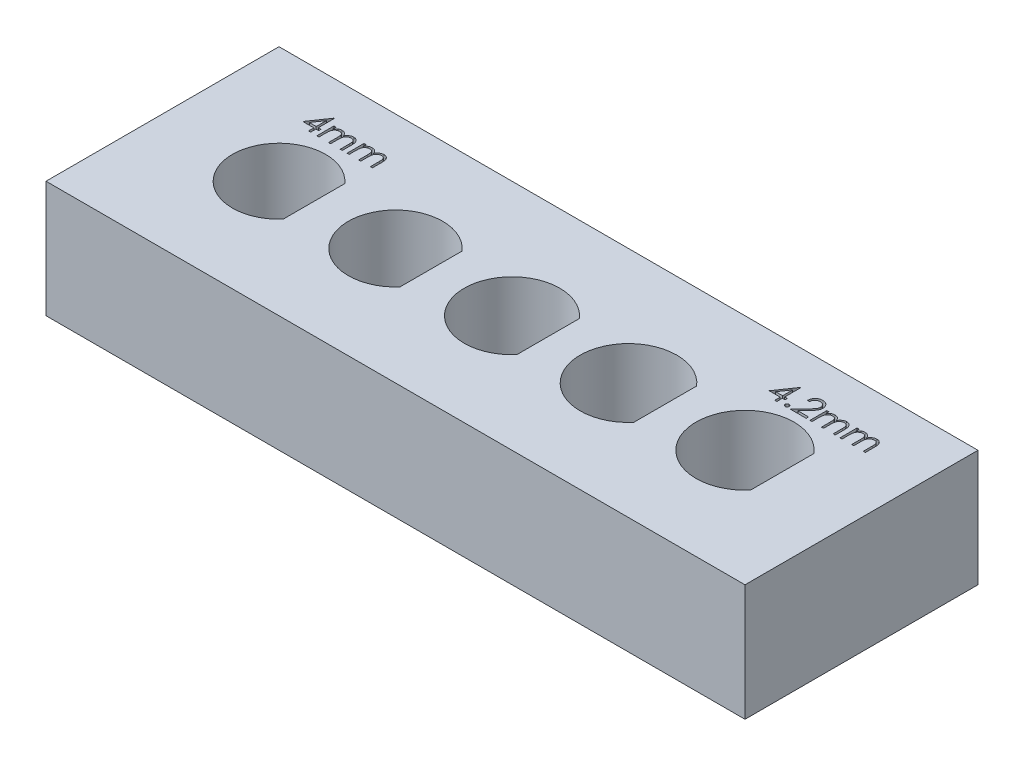
from build123d import *

# Parameters (mm, degrees)
SKETCH1_W           = 30
SKETCH1_H           = 10
BOSS_EXTRUDE1_DEPTH = 5
CUT_EXTRUDE1_DEPTH  = 0.5


with BuildPart() as part:
    # Sketch1 → Boss-Extrude1 (new body)
    with BuildSketch(Plane(origin=(0, 0, 0), x_dir=(1, 0, 0), z_dir=(0, 1, 0))):
        Rectangle(SKETCH1_W, SKETCH1_H)
        with BuildLine():
            ThreePointArc((11.6, 1.360147051), (7.9, 0), (11.6, -1.360147051))
            Line((11.6, -1.360147051), (11.6, 1.360147051))
        make_face(mode=Mode.SUBTRACT)
        with BuildLine():
            ThreePointArc((6.575, 1.350925609), (2.925, 0), (6.575, -1.350925609))
            Line((6.575, -1.350925609), (6.575, 1.350925609))
        make_face(mode=Mode.SUBTRACT)
        with BuildLine():
            ThreePointArc((1.55, 1.341640786), (-2.05, 0), (1.55, -1.341640786))
            Line((1.55, -1.341640786), (1.55, 1.341640786))
        make_face(mode=Mode.SUBTRACT)
        with BuildLine():
            ThreePointArc((-3.475, 1.332291259), (-7.025, 0), (-3.475, -1.332291259))
            Line((-3.475, -1.332291259), (-3.475, 1.332291259))
        make_face(mode=Mode.SUBTRACT)
        with BuildLine():
            ThreePointArc((-8.5, 1.322875656), (-12, 0), (-8.5, -1.322875656))
            Line((-8.5, -1.322875656), (-8.5, 1.322875656))
        make_face(mode=Mode.SUBTRACT)
    extrude(amount=-BOSS_EXTRUDE1_DEPTH)

    # Sketch2 → Cut-Extrude1 (cut)
    with BuildSketch(Plane(origin=(0, 0, 0), x_dir=(1, 0, 0), z_dir=(0, 1, 0))):
        Polygon((-11.16322467, 3.525641026), (-11.144995504, 3.525641026), (-11.144995504, 2.833333333), (-11.029610888, 2.833333333), (-11.029610888, 2.730769231), (-11.144995504, 2.730769231), (-11.144995504, 2.5), (-11.234739093, 2.5), (-11.234739093, 2.730769231), (-11.709098068, 2.730769231), align=None)
        Polygon((-11.234739093, 2.833333333), (-11.234739093, 3.267628205), (-11.532816016, 2.833333333), align=None, mode=Mode.SUBTRACT)
        with BuildLine():
            Line((-10.875764734, 3.230769231), (-10.786021145, 3.230769231))
            Line((-10.786021145, 3.230769231), (-10.786021145, 3.103766026))
            add(Edge.make_bspline(
                [(-10.786021145, 3.103766026), (-10.777940016, 3.114876769), (-10.762455799, 3.136166018), (-10.737065613, 3.164220385), (-10.711701009, 3.18802843), (-10.693434329, 3.200526393), (-10.684658965, 3.206530449)],
                knots=[0, 0, 0, 0, 4.1186e-05, 7.8917e-05, 0.000113372, 0.000145229, 0.000145229, 0.000145229, 0.000145229], degree=3))
            add(Edge.make_bspline(
                [(-10.684658965, 3.206530449), (-10.672697633, 3.212246267), (-10.648983947, 3.223578043), (-10.611435597, 3.235073345), (-10.573014263, 3.24213766), (-10.547069059, 3.243103767), (-10.534017939, 3.243589744)],
                knots=[0, 0, 0, 0, 3.9723e-05, 7.8752e-05, 0.000117418, 0.000156554, 0.000156554, 0.000156554, 0.000156554], degree=3))
            add(Edge.make_bspline(
                [(-10.534017939, 3.243589744), (-10.525191369, 3.243291089), (-10.507724061, 3.242700068), (-10.481842892, 3.238854344), (-10.456740432, 3.232206866), (-10.432564995, 3.22294763), (-10.409787658, 3.211734291), (-10.38890503, 3.198577232), (-10.370155256, 3.183806639), (-10.353547813, 3.166755515), (-10.338613806, 3.146945058), (-10.324876992, 3.123840987), (-10.312184074, 3.096924512), (-10.305149415, 3.077391215), (-10.301445824, 3.067107372)],
                knots=[0, 0, 0, 0, 2.6479e-05, 5.2401e-05, 7.8299e-05, 0.000104231, 0.000129942, 0.00015434, 0.000178148, 0.00020138, 0.000225539, 0.000252404, 0.000281885, 0.000314662, 0.000314662, 0.000314662, 0.000314662], degree=3))
            add(Edge.make_bspline(
                [(-10.301445824, 3.067107372), (-10.297528324, 3.074171492), (-10.289819233, 3.088072687), (-10.276874765, 3.107746477), (-10.263312538, 3.126148417), (-10.249016968, 3.14329311), (-10.234038515, 3.15909589), (-10.218306686, 3.173609005), (-10.201911034, 3.18689478), (-10.179113252, 3.202415683), (-10.149452507, 3.218901734), (-10.112055902, 3.233195576), (-10.073155853, 3.242028755), (-10.046750797, 3.243065976), (-10.033416978, 3.243589744)],
                knots=[0, 0, 0, 0, 2.4226e-05, 4.7672e-05, 7.059e-05, 9.2776e-05, 0.000114597, 0.000135861, 0.000156947, 0.000177839, 0.000218543, 0.000258425, 0.0002976, 0.000337563, 0.000337563, 0.000337563, 0.000337563], degree=3))
            add(Edge.make_bspline(
                [(-10.033416978, 3.243589744), (-10.021165131, 3.24312768), (-9.997187078, 3.242223378), (-9.962279288, 3.235122386), (-9.929724486, 3.222928772), (-9.899588179, 3.20629059), (-9.872399661, 3.185382252), (-9.84876643, 3.160505442), (-9.82883204, 3.131836121), (-9.815809572, 3.104866981), (-9.806976639, 3.081056886), (-9.801530572, 3.060769374), (-9.796719231, 3.038440359), (-9.792724589, 3.014043141), (-9.789805003, 2.987491539), (-9.787641941, 2.958829003), (-9.78617792, 2.928033257), (-9.786074471, 2.906785971), (-9.786021145, 2.895833333)],
                knots=[0, 0, 0, 0, 3.6737e-05, 7.1899e-05, 0.000106317, 0.000140658, 0.000174796, 0.000208802, 0.000243199, 0.000279124, 0.000298327, 0.000319323, 0.000342072, 0.000366837, 0.00039345, 0.00042218, 0.000453061, 0.000485916, 0.000485916, 0.000485916, 0.000485916], degree=3))
            Line((-9.786021145, 2.895833333), (-9.786021145, 2.5))
            Line((-9.786021145, 2.5), (-9.875764734, 2.5))
            Line((-9.875764734, 2.5), (-9.875764734, 2.896233974))
            add(Edge.make_bspline(
                [(-9.875764734, 2.896233974), (-9.875786987, 2.90558271), (-9.875829752, 2.923549557), (-9.876599361, 2.949335972), (-9.878049451, 2.972841217), (-9.879745062, 2.994033242), (-9.882100436, 3.012961467), (-9.885142131, 3.029587873), (-9.888364325, 3.044043247), (-9.893717465, 3.060067832), (-9.902274006, 3.077745035), (-9.915307572, 3.096808914), (-9.931727602, 3.113403429), (-9.950687647, 3.127808662), (-9.972272917, 3.139521131), (-9.996062837, 3.147885705), (-10.021909709, 3.15306367), (-10.039801935, 3.153579675), (-10.049041978, 3.153846154)],
                knots=[0, 0, 0, 0, 2.8046e-05, 5.3899e-05, 7.7379e-05, 9.8689e-05, 0.000117672, 0.000134568, 0.000149388, 0.000162057, 0.000185173, 0.000208067, 0.000231015, 0.000254894, 0.000279275, 0.000304365, 0.000330294, 0.000357985, 0.000357985, 0.000357985, 0.000357985], degree=3))
            add(Edge.make_bspline(
                [(-10.049041978, 3.153846154), (-10.060376251, 3.153441537), (-10.082777082, 3.152641862), (-10.115475793, 3.144477898), (-10.146896083, 3.132169255), (-10.176100407, 3.11433141), (-10.20296549, 3.092957592), (-10.226079655, 3.067543422), (-10.245174565, 3.038792014), (-10.258104273, 3.01217867), (-10.266272644, 2.988273115), (-10.271666049, 2.967388151), (-10.275861304, 2.943650561), (-10.27979574, 2.917219849), (-10.282363663, 2.887914083), (-10.284697483, 2.855868826), (-10.285789159, 2.820987694), (-10.285941861, 2.796808641), (-10.286021145, 2.784254808)],
                knots=[0, 0, 0, 0, 3.3939e-05, 6.7077e-05, 0.000100519, 0.000134839, 0.000169315, 0.000203205, 0.000237429, 0.000272551, 0.000291619, 0.000313143, 0.000337188, 0.000363903, 0.000393284, 0.000425411, 0.000460288, 0.00049795, 0.00049795, 0.00049795, 0.00049795], degree=3))
            Line((-10.286021145, 2.784254808), (-10.286021145, 2.5))
            Line((-10.286021145, 2.5), (-10.375764734, 2.5))
            Line((-10.375764734, 2.5), (-10.375764734, 2.871594551))
            add(Edge.make_bspline(
                [(-10.375764734, 2.871594551), (-10.375787429, 2.882078357), (-10.375831091, 2.902248144), (-10.376595753, 2.931172052), (-10.378049074, 2.957480932), (-10.37972923, 2.981144207), (-10.382146424, 3.002118872), (-10.38489207, 3.020517375), (-10.388134531, 3.036293589), (-10.393503069, 3.053597414), (-10.401707203, 3.072660534), (-10.414903849, 3.09298654), (-10.431363158, 3.110777425), (-10.450669122, 3.125965639), (-10.472385031, 3.138520348), (-10.496380289, 3.147565992), (-10.522438835, 3.152830074), (-10.540403894, 3.153501073), (-10.549642939, 3.153846154)],
                knots=[0, 0, 0, 0, 3.1451e-05, 6.0508e-05, 8.6788e-05, 0.000110494, 0.000131665, 0.000150109, 0.000166296, 0.000179919, 0.000204409, 0.000228301, 0.00025226, 0.000276787, 0.000301733, 0.000327219, 0.000353384, 0.000381087, 0.000381087, 0.000381087, 0.000381087], degree=3))
            add(Edge.make_bspline(
                [(-10.549642939, 3.153846154), (-10.560504714, 3.15340888), (-10.582151845, 3.152537407), (-10.613952408, 3.144693329), (-10.644662603, 3.132406451), (-10.673792517, 3.115360788), (-10.70055656, 3.094246766), (-10.723987493, 3.069413938), (-10.743685358, 3.041171357), (-10.756751591, 3.014838638), (-10.765179726, 2.991531988), (-10.770778393, 2.971717432), (-10.775589715, 2.949717361), (-10.77916515, 2.925463901), (-10.782616697, 2.899115017), (-10.784282499, 2.870539448), (-10.785902946, 2.839761709), (-10.785980779, 2.81851241), (-10.786021145, 2.807491987)],
                knots=[0, 0, 0, 0, 3.2541e-05, 6.4853e-05, 9.7662e-05, 0.000131504, 0.00016573, 0.000199599, 0.000233553, 0.000268671, 0.000287428, 0.000307845, 0.000330399, 0.000354935, 0.000381372, 0.000410087, 0.000440769, 0.000473824, 0.000473824, 0.000473824, 0.000473824], degree=3))
            Line((-10.786021145, 2.807491987), (-10.786021145, 2.5))
            Line((-10.786021145, 2.5), (-10.875764734, 2.5))
            Line((-10.875764734, 2.5), (-10.875764734, 3.230769231))
        make_face()
        with BuildLine():
            Line((-9.580892939, 3.230769231), (-9.49114935, 3.230769231))
            Line((-9.49114935, 3.230769231), (-9.49114935, 3.103766026))
            add(Edge.make_bspline(
                [(-9.49114935, 3.103766026), (-9.483068221, 3.114876769), (-9.467584004, 3.136166018), (-9.442193818, 3.164220385), (-9.416829214, 3.18802843), (-9.398562534, 3.200526393), (-9.38978717, 3.206530449)],
                knots=[0, 0, 0, 0, 4.1186e-05, 7.8917e-05, 0.000113372, 0.000145229, 0.000145229, 0.000145229, 0.000145229], degree=3))
            add(Edge.make_bspline(
                [(-9.38978717, 3.206530449), (-9.377825838, 3.212246267), (-9.354112153, 3.223578043), (-9.316563803, 3.235073345), (-9.278142468, 3.24213766), (-9.252197264, 3.243103767), (-9.239146145, 3.243589744)],
                knots=[0, 0, 0, 0, 3.9723e-05, 7.8752e-05, 0.000117418, 0.000156554, 0.000156554, 0.000156554, 0.000156554], degree=3))
            add(Edge.make_bspline(
                [(-9.239146145, 3.243589744), (-9.230319574, 3.243291089), (-9.212852266, 3.242700068), (-9.186971097, 3.238854344), (-9.161868637, 3.232206866), (-9.1376932, 3.22294763), (-9.114915863, 3.211734291), (-9.094033235, 3.198577232), (-9.075283461, 3.183806639), (-9.058676018, 3.166755515), (-9.043742011, 3.146945058), (-9.030005197, 3.123840987), (-9.01731228, 3.096924512), (-9.01027762, 3.077391215), (-9.006574029, 3.067107372)],
                knots=[0, 0, 0, 0, 2.6479e-05, 5.2401e-05, 7.8299e-05, 0.000104231, 0.000129942, 0.00015434, 0.000178148, 0.00020138, 0.000225539, 0.000252404, 0.000281885, 0.000314662, 0.000314662, 0.000314662, 0.000314662], degree=3))
            add(Edge.make_bspline(
                [(-9.006574029, 3.067107372), (-9.002656529, 3.074171492), (-8.994947438, 3.088072687), (-8.98200297, 3.107746477), (-8.968440743, 3.126148417), (-8.954145173, 3.14329311), (-8.93916672, 3.15909589), (-8.923434891, 3.173609005), (-8.90703924, 3.18689478), (-8.884241457, 3.202415683), (-8.854580712, 3.218901734), (-8.817184108, 3.233195576), (-8.778284059, 3.242028755), (-8.751879002, 3.243065976), (-8.738545183, 3.243589744)],
                knots=[0, 0, 0, 0, 2.4226e-05, 4.7672e-05, 7.059e-05, 9.2776e-05, 0.000114597, 0.000135861, 0.000156947, 0.000177839, 0.000218543, 0.000258425, 0.0002976, 0.000337563, 0.000337563, 0.000337563, 0.000337563], degree=3))
            add(Edge.make_bspline(
                [(-8.738545183, 3.243589744), (-8.726293337, 3.24312768), (-8.702315283, 3.242223378), (-8.667407493, 3.235122386), (-8.634852692, 3.222928772), (-8.604716384, 3.20629059), (-8.577527866, 3.185382252), (-8.553894635, 3.160505442), (-8.533960245, 3.131836121), (-8.520937777, 3.104866981), (-8.512104844, 3.081056886), (-8.506658777, 3.060769374), (-8.501847436, 3.038440359), (-8.497852794, 3.014043141), (-8.494933208, 2.987491539), (-8.492770146, 2.958829003), (-8.491306125, 2.928033257), (-8.491202676, 2.906785971), (-8.49114935, 2.895833333)],
                knots=[0, 0, 0, 0, 3.6737e-05, 7.1899e-05, 0.000106317, 0.000140658, 0.000174796, 0.000208802, 0.000243199, 0.000279124, 0.000298327, 0.000319323, 0.000342072, 0.000366837, 0.00039345, 0.00042218, 0.000453061, 0.000485916, 0.000485916, 0.000485916, 0.000485916], degree=3))
            Line((-8.49114935, 2.895833333), (-8.49114935, 2.5))
            Line((-8.49114935, 2.5), (-8.580892939, 2.5))
            Line((-8.580892939, 2.5), (-8.580892939, 2.896233974))
            add(Edge.make_bspline(
                [(-8.580892939, 2.896233974), (-8.580915192, 2.90558271), (-8.580957957, 2.923549557), (-8.581727566, 2.949335972), (-8.583177656, 2.972841217), (-8.584873267, 2.994033242), (-8.587228641, 3.012961467), (-8.590270336, 3.029587873), (-8.59349253, 3.044043247), (-8.598845671, 3.060067832), (-8.607402211, 3.077745035), (-8.620435777, 3.096808914), (-8.636855807, 3.113403429), (-8.655815852, 3.127808662), (-8.677401122, 3.139521131), (-8.701191043, 3.147885705), (-8.727037915, 3.15306367), (-8.74493014, 3.153579675), (-8.754170183, 3.153846154)],
                knots=[0, 0, 0, 0, 2.8046e-05, 5.3899e-05, 7.7379e-05, 9.8689e-05, 0.000117672, 0.000134568, 0.000149388, 0.000162057, 0.000185173, 0.000208067, 0.000231015, 0.000254894, 0.000279275, 0.000304365, 0.000330294, 0.000357985, 0.000357985, 0.000357985, 0.000357985], degree=3))
            add(Edge.make_bspline(
                [(-8.754170183, 3.153846154), (-8.765504456, 3.153441537), (-8.787905287, 3.152641862), (-8.820603998, 3.144477898), (-8.852024288, 3.132169255), (-8.881228612, 3.11433141), (-8.908093695, 3.092957592), (-8.93120786, 3.067543422), (-8.95030277, 3.038792014), (-8.963232478, 3.01217867), (-8.971400849, 2.988273115), (-8.976794254, 2.967388151), (-8.980989509, 2.943650561), (-8.984923946, 2.917219849), (-8.987491868, 2.887914083), (-8.989825689, 2.855868826), (-8.990917364, 2.820987694), (-8.991070066, 2.796808641), (-8.99114935, 2.784254808)],
                knots=[0, 0, 0, 0, 3.3939e-05, 6.7077e-05, 0.000100519, 0.000134839, 0.000169315, 0.000203205, 0.000237429, 0.000272551, 0.000291619, 0.000313143, 0.000337188, 0.000363903, 0.000393284, 0.000425411, 0.000460288, 0.00049795, 0.00049795, 0.00049795, 0.00049795], degree=3))
            Line((-8.99114935, 2.784254808), (-8.99114935, 2.5))
            Line((-8.99114935, 2.5), (-9.080892939, 2.5))
            Line((-9.080892939, 2.5), (-9.080892939, 2.871594551))
            add(Edge.make_bspline(
                [(-9.080892939, 2.871594551), (-9.080915634, 2.882078357), (-9.080959296, 2.902248144), (-9.081723958, 2.931172052), (-9.083177279, 2.957480932), (-9.084857435, 2.981144207), (-9.087274629, 3.002118872), (-9.090020276, 3.020517375), (-9.093262736, 3.036293589), (-9.098631274, 3.053597414), (-9.106835408, 3.072660534), (-9.120032054, 3.09298654), (-9.136491363, 3.110777425), (-9.155797327, 3.125965639), (-9.177513237, 3.138520348), (-9.201508494, 3.147565992), (-9.227567041, 3.152830074), (-9.245532099, 3.153501073), (-9.254771145, 3.153846154)],
                knots=[0, 0, 0, 0, 3.1451e-05, 6.0508e-05, 8.6788e-05, 0.000110494, 0.000131665, 0.000150109, 0.000166296, 0.000179919, 0.000204409, 0.000228301, 0.00025226, 0.000276787, 0.000301733, 0.000327219, 0.000353384, 0.000381087, 0.000381087, 0.000381087, 0.000381087], degree=3))
            add(Edge.make_bspline(
                [(-9.254771145, 3.153846154), (-9.265632919, 3.15340888), (-9.287280051, 3.152537407), (-9.319080613, 3.144693329), (-9.349790809, 3.132406451), (-9.378920723, 3.115360788), (-9.405684765, 3.094246766), (-9.429115698, 3.069413938), (-9.448813563, 3.041171357), (-9.461879796, 3.014838638), (-9.470307931, 2.991531988), (-9.475906598, 2.971717432), (-9.48071792, 2.949717361), (-9.484293355, 2.925463901), (-9.487744902, 2.899115017), (-9.489410705, 2.870539448), (-9.491031151, 2.839761709), (-9.491108984, 2.81851241), (-9.49114935, 2.807491987)],
                knots=[0, 0, 0, 0, 3.2541e-05, 6.4853e-05, 9.7662e-05, 0.000131504, 0.00016573, 0.000199599, 0.000233553, 0.000268671, 0.000287428, 0.000307845, 0.000330399, 0.000354935, 0.000381372, 0.000410087, 0.000440769, 0.000473824, 0.000473824, 0.000473824, 0.000473824], degree=3))
            Line((-9.49114935, 2.807491987), (-9.49114935, 2.5))
            Line((-9.49114935, 2.5), (-9.580892939, 2.5))
            Line((-9.580892939, 2.5), (-9.580892939, 3.230769231))
        make_face()
        Polygon((8.852364677, 3.525641026), (8.870593843, 3.525641026), (8.870593843, 2.833333333), (8.985978459, 2.833333333), (8.985978459, 2.730769231), (8.870593843, 2.730769231), (8.870593843, 2.5), (8.780850254, 2.5), (8.780850254, 2.730769231), (8.306491279, 2.730769231), align=None)
        Polygon((8.780850254, 2.833333333), (8.780850254, 3.267628205), (8.48277333, 2.833333333), align=None, mode=Mode.SUBTRACT)
        with BuildLine():
            add(Edge.make_bspline(
                [(9.235978459, 2.653846154), (9.241547091, 2.653515249), (9.252463743, 2.652866549), (9.268246351, 2.648416071), (9.282530539, 2.640513596), (9.295254038, 2.629981374), (9.305741603, 2.617211184), (9.313925703, 2.603040925), (9.318337413, 2.587126184), (9.318981388, 2.576146277), (9.319311792, 2.570512821)],
                knots=[0, 0, 0, 0, 1.6704e-05, 3.2746e-05, 4.8701e-05, 6.5347e-05, 8.1993e-05, 9.8045e-05, 0.000114087, 0.00013099, 0.00013099, 0.00013099, 0.00013099], degree=3))
            add(Edge.make_bspline(
                [(9.319311792, 2.570512821), (9.318970192, 2.565014726), (9.318296561, 2.554172565), (9.313935816, 2.538377862), (9.30567923, 2.524198746), (9.295326375, 2.511255278), (9.282527394, 2.500700744), (9.268212581, 2.492865502), (9.252500793, 2.488096365), (9.241553272, 2.487488852), (9.235978459, 2.487179487)],
                knots=[0, 0, 0, 0, 1.6504e-05, 3.2546e-05, 4.8598e-05, 6.5399e-05, 8.2045e-05, 9.8e-05, 0.000114098, 0.000130802, 0.000130802, 0.000130802, 0.000130802], degree=3))
            add(Edge.make_bspline(
                [(9.235978459, 2.487179487), (9.230399628, 2.487477658), (9.219508291, 2.488059765), (9.203855149, 2.492963424), (9.189453158, 2.50062727), (9.176656669, 2.511274958), (9.166217106, 2.524132142), (9.158324139, 2.538475512), (9.153584097, 2.554127352), (9.152960705, 2.565005821), (9.152645125, 2.570512821)],
                knots=[0, 0, 0, 0, 1.6704e-05, 3.261e-05, 4.8742e-05, 6.5388e-05, 8.2188e-05, 9.8144e-05, 0.000114242, 0.000130746, 0.000130746, 0.000130746, 0.000130746], degree=3))
            add(Edge.make_bspline(
                [(9.152645125, 2.570512821), (9.152948582, 2.5761555), (9.153541045, 2.58717214), (9.15833409, 2.602943314), (9.166155865, 2.617277154), (9.176728835, 2.629961891), (9.189450063, 2.640586835), (9.203820407, 2.648319633), (9.21954599, 2.652902608), (9.230405972, 2.653526184), (9.235978459, 2.653846154)],
                knots=[0, 0, 0, 0, 1.6903e-05, 3.3001e-05, 4.8957e-05, 6.5602e-05, 8.2248e-05, 9.838e-05, 0.000114229, 0.000130933, 0.000130933, 0.000130933, 0.000130933], degree=3))
        make_face()
        with BuildLine():
            Line((9.575722048, 3.192307692), (9.485978459, 3.192307692))
            add(Edge.make_bspline(
                [(9.485978459, 3.192307692), (9.48656336, 3.20421366), (9.487712089, 3.227596664), (9.4930916, 3.261689209), (9.500788994, 3.294276294), (9.511672267, 3.32509627), (9.525188346, 3.354421643), (9.541396925, 3.382135934), (9.560595168, 3.408133416), (9.582368521, 3.432173086), (9.606016703, 3.454226677), (9.631532686, 3.473271032), (9.658345551, 3.489361796), (9.686373951, 3.502813579), (9.715934112, 3.512910678), (9.746757785, 3.520402575), (9.778980396, 3.524910102), (9.800934688, 3.525394612), (9.812100254, 3.525641026)],
                knots=[0, 0, 0, 0, 3.5738e-05, 7.0188e-05, 0.000103373, 0.000136064, 0.000168061, 0.000200116, 0.000232208, 0.000264831, 0.000297294, 0.000329065, 0.000360156, 0.00039098, 0.000422149, 0.000453681, 0.000486034, 0.000519517, 0.000519517, 0.000519517, 0.000519517], degree=3))
            add(Edge.make_bspline(
                [(9.812100254, 3.525641026), (9.823065418, 3.525384324), (9.844611573, 3.524879914), (9.876057863, 3.520548191), (9.905994233, 3.513763736), (9.934362166, 3.504245046), (9.960935327, 3.491449495), (9.98591334, 3.47607877), (10.009593572, 3.458301675), (10.030909796, 3.437372014), (10.050483533, 3.415028476), (10.067369891, 3.391174789), (10.081830795, 3.36653785), (10.093884418, 3.340929793), (10.1027576, 3.314109499), (10.109494231, 3.286467441), (10.113302064, 3.257717495), (10.113886471, 3.238258479), (10.114183587, 3.228365385)],
                knots=[0, 0, 0, 0, 3.2882e-05, 6.4613e-05, 9.5033e-05, 0.00012487, 0.000154169, 0.000183303, 0.000212751, 0.000242786, 0.000272749, 0.000301764, 0.000330315, 0.000358367, 0.000386493, 0.000414917, 0.000443616, 0.000473296, 0.000473296, 0.000473296, 0.000473296], degree=3))
            add(Edge.make_bspline(
                [(10.114183587, 3.228365385), (10.113699797, 3.214437432), (10.112740709, 3.186825942), (10.104536601, 3.146250267), (10.091723312, 3.106937862), (10.076295496, 3.075298633), (10.06073194, 3.049803349), (10.046706938, 3.02881229), (10.030288421, 3.006210728), (10.011237421, 2.982074346), (9.989948029, 2.956214087), (9.966227411, 2.928645574), (9.939906416, 2.89965364), (9.921432559, 2.879852039), (9.911859869, 2.869591346)],
                knots=[0, 0, 0, 0, 4.1748e-05, 8.2763e-05, 0.000123686, 0.000165526, 0.000187994, 0.000213273, 0.000241241, 0.000271777, 0.000305505, 0.000341726, 0.000380871, 0.000422969, 0.000422969, 0.000422969, 0.000422969], degree=3))
            Line((9.911859869, 2.869591346), (9.661659548, 2.602564103))
            Line((9.661659548, 2.602564103), (10.1270041, 2.602564103))
            Line((10.1270041, 2.602564103), (10.1270041, 2.5))
            Line((10.1270041, 2.5), (9.44751692, 2.5))
            Line((9.44751692, 2.5), (9.835337433, 2.913862179))
            add(Edge.make_bspline(
                [(9.835337433, 2.913862179), (9.844779686, 2.923718839), (9.862916323, 2.942651463), (9.888568487, 2.970292309), (9.911608198, 2.995935035), (9.932184596, 3.019531192), (9.949851312, 3.041425925), (9.965529093, 3.060910126), (9.97809069, 3.078839969), (9.99172366, 3.099623002), (10.004927655, 3.12499795), (10.016274042, 3.156007575), (10.023192571, 3.187929647), (10.024022524, 3.209501658), (10.024439997, 3.220352564)],
                knots=[0, 0, 0, 0, 4.0948e-05, 7.8653e-05, 0.000113123, 0.000144368, 0.000172557, 0.000197523, 0.000219366, 0.000238203, 0.000272071, 0.000304896, 0.000337034, 0.00036956, 0.00036956, 0.00036956, 0.00036956], degree=3))
            add(Edge.make_bspline(
                [(10.024439997, 3.220352564), (10.024258356, 3.227175821), (10.023900378, 3.240623149), (10.020741035, 3.260339081), (10.015966605, 3.279357599), (10.009125103, 3.297737204), (10.000094606, 3.315293105), (9.989102211, 3.332046671), (9.976419336, 3.348243518), (9.961747545, 3.363430174), (9.945629968, 3.37733909), (9.928603039, 3.389660258), (9.910588724, 3.399957146), (9.891662975, 3.408398146), (9.871878555, 3.415019683), (9.851197199, 3.419607849), (9.829676052, 3.422488558), (9.814980767, 3.422878322), (9.807492882, 3.423076923)],
                knots=[0, 0, 0, 0, 2.0457e-05, 4.0317e-05, 5.9751e-05, 7.9211e-05, 9.9011e-05, 0.000118847, 0.000139245, 0.000160638, 0.000182083, 0.000203042, 0.00022359, 0.000244214, 0.000265119, 0.000286064, 0.000307681, 0.00033014, 0.00033014, 0.00033014, 0.00033014], degree=3))
            add(Edge.make_bspline(
                [(9.807492882, 3.423076923), (9.799672644, 3.422872628), (9.784314988, 3.422471427), (9.761766693, 3.419664951), (9.74025647, 3.414823283), (9.719730212, 3.408201376), (9.700153188, 3.399784647), (9.681620604, 3.389301292), (9.664174064, 3.376791722), (9.647780772, 3.362608706), (9.632676778, 3.346817963), (9.619406242, 3.329215116), (9.607810809, 3.310121569), (9.597693885, 3.28958884), (9.589477974, 3.267430617), (9.583199931, 3.243725559), (9.57823226, 3.218576593), (9.576572683, 3.201209426), (9.575722048, 3.192307692)],
                knots=[0, 0, 0, 0, 2.3459e-05, 4.6069e-05, 6.8036e-05, 8.9512e-05, 0.000110686, 0.000131856, 0.000153256, 0.000174984, 0.000196805, 0.000218681, 0.000240978, 0.000263733, 0.000287249, 0.000311741, 0.000337238, 0.00036405, 0.00036405, 0.00036405, 0.00036405], degree=3))
        make_face()
        with BuildLine():
            Line((10.280850254, 3.230769231), (10.370593843, 3.230769231))
            Line((10.370593843, 3.230769231), (10.370593843, 3.103766026))
            add(Edge.make_bspline(
                [(10.370593843, 3.103766026), (10.378674972, 3.114876769), (10.394159189, 3.136166018), (10.419549375, 3.164220385), (10.444913979, 3.18802843), (10.463180659, 3.200526393), (10.471956023, 3.206530449)],
                knots=[0, 0, 0, 0, 4.1186e-05, 7.8917e-05, 0.000113372, 0.000145229, 0.000145229, 0.000145229, 0.000145229], degree=3))
            add(Edge.make_bspline(
                [(10.471956023, 3.206530449), (10.483917355, 3.212246267), (10.50763104, 3.223578043), (10.54517939, 3.235073345), (10.583600725, 3.24213766), (10.609545929, 3.243103767), (10.622597048, 3.243589744)],
                knots=[0, 0, 0, 0, 3.9723e-05, 7.8752e-05, 0.000117418, 0.000156554, 0.000156554, 0.000156554, 0.000156554], degree=3))
            add(Edge.make_bspline(
                [(10.622597048, 3.243589744), (10.631423619, 3.243291089), (10.648890927, 3.242700068), (10.674772096, 3.238854344), (10.699874556, 3.232206866), (10.724049993, 3.22294763), (10.74682733, 3.211734291), (10.767709958, 3.198577232), (10.786459732, 3.183806639), (10.803067175, 3.166755515), (10.818001182, 3.146945058), (10.831737996, 3.123840987), (10.844430913, 3.096924512), (10.851465573, 3.077391215), (10.855169164, 3.067107372)],
                knots=[0, 0, 0, 0, 2.6479e-05, 5.2401e-05, 7.8299e-05, 0.000104231, 0.000129942, 0.00015434, 0.000178148, 0.00020138, 0.000225539, 0.000252404, 0.000281885, 0.000314662, 0.000314662, 0.000314662, 0.000314662], degree=3))
            add(Edge.make_bspline(
                [(10.855169164, 3.067107372), (10.859086664, 3.074171492), (10.866795755, 3.088072687), (10.879740223, 3.107746477), (10.89330245, 3.126148417), (10.90759802, 3.14329311), (10.922576473, 3.15909589), (10.938308302, 3.173609005), (10.954703953, 3.18689478), (10.977501736, 3.202415683), (11.007162481, 3.218901734), (11.044559085, 3.233195576), (11.083459134, 3.242028755), (11.109864191, 3.243065976), (11.12319801, 3.243589744)],
                knots=[0, 0, 0, 0, 2.4226e-05, 4.7672e-05, 7.059e-05, 9.2776e-05, 0.000114597, 0.000135861, 0.000156947, 0.000177839, 0.000218543, 0.000258425, 0.0002976, 0.000337563, 0.000337563, 0.000337563, 0.000337563], degree=3))
            add(Edge.make_bspline(
                [(11.12319801, 3.243589744), (11.135449856, 3.24312768), (11.15942791, 3.242223378), (11.1943357, 3.235122386), (11.226890501, 3.222928772), (11.257026809, 3.20629059), (11.284215327, 3.185382252), (11.307848558, 3.160505442), (11.327782948, 3.131836121), (11.340805416, 3.104866981), (11.349638349, 3.081056886), (11.355084416, 3.060769374), (11.359895757, 3.038440359), (11.363890399, 3.014043141), (11.366809985, 2.987491539), (11.368973047, 2.958829003), (11.370437068, 2.928033257), (11.370540517, 2.906785971), (11.370593843, 2.895833333)],
                knots=[0, 0, 0, 0, 3.6737e-05, 7.1899e-05, 0.000106317, 0.000140658, 0.000174796, 0.000208802, 0.000243199, 0.000279124, 0.000298327, 0.000319323, 0.000342072, 0.000366837, 0.00039345, 0.00042218, 0.000453061, 0.000485916, 0.000485916, 0.000485916, 0.000485916], degree=3))
            Line((11.370593843, 2.895833333), (11.370593843, 2.5))
            Line((11.370593843, 2.5), (11.280850254, 2.5))
            Line((11.280850254, 2.5), (11.280850254, 2.896233974))
            add(Edge.make_bspline(
                [(11.280850254, 2.896233974), (11.280828001, 2.90558271), (11.280785236, 2.923549557), (11.280015627, 2.949335972), (11.278565537, 2.972841217), (11.276869926, 2.994033242), (11.274514552, 3.012961467), (11.271472857, 3.029587873), (11.268250663, 3.044043247), (11.262897522, 3.060067832), (11.254340982, 3.077745035), (11.241307416, 3.096808914), (11.224887386, 3.113403429), (11.205927341, 3.127808662), (11.184342071, 3.139521131), (11.16055215, 3.147885705), (11.134705278, 3.15306367), (11.116813053, 3.153579675), (11.10757301, 3.153846154)],
                knots=[0, 0, 0, 0, 2.8046e-05, 5.3899e-05, 7.7379e-05, 9.8689e-05, 0.000117672, 0.000134568, 0.000149388, 0.000162057, 0.000185173, 0.000208067, 0.000231015, 0.000254894, 0.000279275, 0.000304365, 0.000330294, 0.000357985, 0.000357985, 0.000357985, 0.000357985], degree=3))
            add(Edge.make_bspline(
                [(11.10757301, 3.153846154), (11.096238737, 3.153441537), (11.073837905, 3.152641862), (11.041139195, 3.144477898), (11.009718905, 3.132169255), (10.980514581, 3.11433141), (10.953649498, 3.092957592), (10.930535333, 3.067543422), (10.911440423, 3.038792014), (10.898510715, 3.01217867), (10.890342343, 2.988273115), (10.884948939, 2.967388151), (10.880753684, 2.943650561), (10.876819247, 2.917219849), (10.874251325, 2.887914083), (10.871917504, 2.855868826), (10.870825829, 2.820987694), (10.870673127, 2.796808641), (10.870593843, 2.784254808)],
                knots=[0, 0, 0, 0, 3.3939e-05, 6.7077e-05, 0.000100519, 0.000134839, 0.000169315, 0.000203205, 0.000237429, 0.000272551, 0.000291619, 0.000313143, 0.000337188, 0.000363903, 0.000393284, 0.000425411, 0.000460288, 0.00049795, 0.00049795, 0.00049795, 0.00049795], degree=3))
            Line((10.870593843, 2.784254808), (10.870593843, 2.5))
            Line((10.870593843, 2.5), (10.780850254, 2.5))
            Line((10.780850254, 2.5), (10.780850254, 2.871594551))
            add(Edge.make_bspline(
                [(10.780850254, 2.871594551), (10.780827559, 2.882078357), (10.780783897, 2.902248144), (10.780019235, 2.931172052), (10.778565914, 2.957480932), (10.776885758, 2.981144207), (10.774468564, 3.002118872), (10.771722917, 3.020517375), (10.768480457, 3.036293589), (10.763111919, 3.053597414), (10.754907785, 3.072660534), (10.741711139, 3.09298654), (10.72525183, 3.110777425), (10.705945866, 3.125965639), (10.684229956, 3.138520348), (10.660234699, 3.147565992), (10.634176152, 3.152830074), (10.616211094, 3.153501073), (10.606972048, 3.153846154)],
                knots=[0, 0, 0, 0, 3.1451e-05, 6.0508e-05, 8.6788e-05, 0.000110494, 0.000131665, 0.000150109, 0.000166296, 0.000179919, 0.000204409, 0.000228301, 0.00025226, 0.000276787, 0.000301733, 0.000327219, 0.000353384, 0.000381087, 0.000381087, 0.000381087, 0.000381087], degree=3))
            add(Edge.make_bspline(
                [(10.606972048, 3.153846154), (10.596110274, 3.15340888), (10.574463142, 3.152537407), (10.54266258, 3.144693329), (10.511952384, 3.132406451), (10.48282247, 3.115360788), (10.456058428, 3.094246766), (10.432627495, 3.069413938), (10.41292963, 3.041171357), (10.399863397, 3.014838638), (10.391435262, 2.991531988), (10.385836595, 2.971717432), (10.381025273, 2.949717361), (10.377449838, 2.925463901), (10.373998291, 2.899115017), (10.372332488, 2.870539448), (10.370712042, 2.839761709), (10.370634209, 2.81851241), (10.370593843, 2.807491987)],
                knots=[0, 0, 0, 0, 3.2541e-05, 6.4853e-05, 9.7662e-05, 0.000131504, 0.00016573, 0.000199599, 0.000233553, 0.000268671, 0.000287428, 0.000307845, 0.000330399, 0.000354935, 0.000381372, 0.000410087, 0.000440769, 0.000473824, 0.000473824, 0.000473824, 0.000473824], degree=3))
            Line((10.370593843, 2.807491987), (10.370593843, 2.5))
            Line((10.370593843, 2.5), (10.280850254, 2.5))
            Line((10.280850254, 2.5), (10.280850254, 3.230769231))
        make_face()
        with BuildLine():
            Line((11.575722048, 3.230769231), (11.665465638, 3.230769231))
            Line((11.665465638, 3.230769231), (11.665465638, 3.103766026))
            add(Edge.make_bspline(
                [(11.665465638, 3.103766026), (11.673546767, 3.114876769), (11.689030984, 3.136166018), (11.71442117, 3.164220385), (11.739785774, 3.18802843), (11.758052454, 3.200526393), (11.766827818, 3.206530449)],
                knots=[0, 0, 0, 0, 4.1186e-05, 7.8917e-05, 0.000113372, 0.000145229, 0.000145229, 0.000145229, 0.000145229], degree=3))
            add(Edge.make_bspline(
                [(11.766827818, 3.206530449), (11.77878915, 3.212246267), (11.802502835, 3.223578043), (11.840051185, 3.235073345), (11.878472519, 3.24213766), (11.904417723, 3.243103767), (11.917468843, 3.243589744)],
                knots=[0, 0, 0, 0, 3.9723e-05, 7.8752e-05, 0.000117418, 0.000156554, 0.000156554, 0.000156554, 0.000156554], degree=3))
            add(Edge.make_bspline(
                [(11.917468843, 3.243589744), (11.926295414, 3.243291089), (11.943762722, 3.242700068), (11.969643891, 3.238854344), (11.994746351, 3.232206866), (12.018921788, 3.22294763), (12.041699125, 3.211734291), (12.062581753, 3.198577232), (12.081331527, 3.183806639), (12.09793897, 3.166755515), (12.112872977, 3.146945058), (12.126609791, 3.123840987), (12.139302708, 3.096924512), (12.146337368, 3.077391215), (12.150040959, 3.067107372)],
                knots=[0, 0, 0, 0, 2.6479e-05, 5.2401e-05, 7.8299e-05, 0.000104231, 0.000129942, 0.00015434, 0.000178148, 0.00020138, 0.000225539, 0.000252404, 0.000281885, 0.000314662, 0.000314662, 0.000314662, 0.000314662], degree=3))
            add(Edge.make_bspline(
                [(12.150040959, 3.067107372), (12.153958459, 3.074171492), (12.16166755, 3.088072687), (12.174612017, 3.107746477), (12.188174245, 3.126148417), (12.202469814, 3.14329311), (12.217448268, 3.15909589), (12.233180096, 3.173609005), (12.249575748, 3.18689478), (12.272373531, 3.202415683), (12.302034276, 3.218901734), (12.33943088, 3.233195576), (12.378330929, 3.242028755), (12.404735986, 3.243065976), (12.418069805, 3.243589744)],
                knots=[0, 0, 0, 0, 2.4226e-05, 4.7672e-05, 7.059e-05, 9.2776e-05, 0.000114597, 0.000135861, 0.000156947, 0.000177839, 0.000218543, 0.000258425, 0.0002976, 0.000337563, 0.000337563, 0.000337563, 0.000337563], degree=3))
            add(Edge.make_bspline(
                [(12.418069805, 3.243589744), (12.430321651, 3.24312768), (12.454299705, 3.242223378), (12.489207495, 3.235122386), (12.521762296, 3.222928772), (12.551898604, 3.20629059), (12.579087122, 3.185382252), (12.602720353, 3.160505442), (12.622654743, 3.131836121), (12.635677211, 3.104866981), (12.644510144, 3.081056886), (12.649956211, 3.060769374), (12.654767552, 3.038440359), (12.658762194, 3.014043141), (12.66168178, 2.987491539), (12.663844841, 2.958829003), (12.665308862, 2.928033257), (12.665412312, 2.906785971), (12.665465638, 2.895833333)],
                knots=[0, 0, 0, 0, 3.6737e-05, 7.1899e-05, 0.000106317, 0.000140658, 0.000174796, 0.000208802, 0.000243199, 0.000279124, 0.000298327, 0.000319323, 0.000342072, 0.000366837, 0.00039345, 0.00042218, 0.000453061, 0.000485916, 0.000485916, 0.000485916, 0.000485916], degree=3))
            Line((12.665465638, 2.895833333), (12.665465638, 2.5))
            Line((12.665465638, 2.5), (12.575722048, 2.5))
            Line((12.575722048, 2.5), (12.575722048, 2.896233974))
            add(Edge.make_bspline(
                [(12.575722048, 2.896233974), (12.575699796, 2.90558271), (12.575657031, 2.923549557), (12.574887422, 2.949335972), (12.573437332, 2.972841217), (12.571741721, 2.994033242), (12.569386347, 3.012961467), (12.566344652, 3.029587873), (12.563122458, 3.044043247), (12.557769317, 3.060067832), (12.549212777, 3.077745035), (12.536179211, 3.096808914), (12.519759181, 3.113403429), (12.500799136, 3.127808662), (12.479213866, 3.139521131), (12.455423945, 3.147885705), (12.429577073, 3.15306367), (12.411684848, 3.153579675), (12.402444805, 3.153846154)],
                knots=[0, 0, 0, 0, 2.8046e-05, 5.3899e-05, 7.7379e-05, 9.8689e-05, 0.000117672, 0.000134568, 0.000149388, 0.000162057, 0.000185173, 0.000208067, 0.000231015, 0.000254894, 0.000279275, 0.000304365, 0.000330294, 0.000357985, 0.000357985, 0.000357985, 0.000357985], degree=3))
            add(Edge.make_bspline(
                [(12.402444805, 3.153846154), (12.391110532, 3.153441537), (12.3687097, 3.152641862), (12.33601099, 3.144477898), (12.3045907, 3.132169255), (12.275386376, 3.11433141), (12.248521293, 3.092957592), (12.225407128, 3.067543422), (12.206312218, 3.038792014), (12.19338251, 3.01217867), (12.185214138, 2.988273115), (12.179820734, 2.967388151), (12.175625479, 2.943650561), (12.171691042, 2.917219849), (12.16912312, 2.887914083), (12.166789299, 2.855868826), (12.165697624, 2.820987694), (12.165544922, 2.796808641), (12.165465638, 2.784254808)],
                knots=[0, 0, 0, 0, 3.3939e-05, 6.7077e-05, 0.000100519, 0.000134839, 0.000169315, 0.000203205, 0.000237429, 0.000272551, 0.000291619, 0.000313143, 0.000337188, 0.000363903, 0.000393284, 0.000425411, 0.000460288, 0.00049795, 0.00049795, 0.00049795, 0.00049795], degree=3))
            Line((12.165465638, 2.784254808), (12.165465638, 2.5))
            Line((12.165465638, 2.5), (12.075722048, 2.5))
            Line((12.075722048, 2.5), (12.075722048, 2.871594551))
            add(Edge.make_bspline(
                [(12.075722048, 2.871594551), (12.075699354, 2.882078357), (12.075655692, 2.902248144), (12.07489103, 2.931172052), (12.073437709, 2.957480932), (12.071757553, 2.981144207), (12.069340359, 3.002118872), (12.066594712, 3.020517375), (12.063352252, 3.036293589), (12.057983714, 3.053597414), (12.04977958, 3.072660534), (12.036582934, 3.09298654), (12.020123625, 3.110777425), (12.00081766, 3.125965639), (11.979101751, 3.138520348), (11.955106494, 3.147565992), (11.929047947, 3.152830074), (11.911082888, 3.153501073), (11.901843843, 3.153846154)],
                knots=[0, 0, 0, 0, 3.1451e-05, 6.0508e-05, 8.6788e-05, 0.000110494, 0.000131665, 0.000150109, 0.000166296, 0.000179919, 0.000204409, 0.000228301, 0.00025226, 0.000276787, 0.000301733, 0.000327219, 0.000353384, 0.000381087, 0.000381087, 0.000381087, 0.000381087], degree=3))
            add(Edge.make_bspline(
                [(11.901843843, 3.153846154), (11.890982069, 3.15340888), (11.869334937, 3.152537407), (11.837534375, 3.144693329), (11.806824179, 3.132406451), (11.777694265, 3.115360788), (11.750930223, 3.094246766), (11.727499289, 3.069413938), (11.707801425, 3.041171357), (11.694735192, 3.014838638), (11.686307057, 2.991531988), (11.68070839, 2.971717432), (11.675897068, 2.949717361), (11.672321633, 2.925463901), (11.668870086, 2.899115017), (11.667204283, 2.870539448), (11.665583837, 2.839761709), (11.665506004, 2.81851241), (11.665465638, 2.807491987)],
                knots=[0, 0, 0, 0, 3.2541e-05, 6.4853e-05, 9.7662e-05, 0.000131504, 0.00016573, 0.000199599, 0.000233553, 0.000268671, 0.000287428, 0.000307845, 0.000330399, 0.000354935, 0.000381372, 0.000410087, 0.000440769, 0.000473824, 0.000473824, 0.000473824, 0.000473824], degree=3))
            Line((11.665465638, 2.807491987), (11.665465638, 2.5))
            Line((11.665465638, 2.5), (11.575722048, 2.5))
            Line((11.575722048, 2.5), (11.575722048, 3.230769231))
        make_face()
    extrude(amount=-CUT_EXTRUDE1_DEPTH, mode=Mode.SUBTRACT)


solid = part.part
